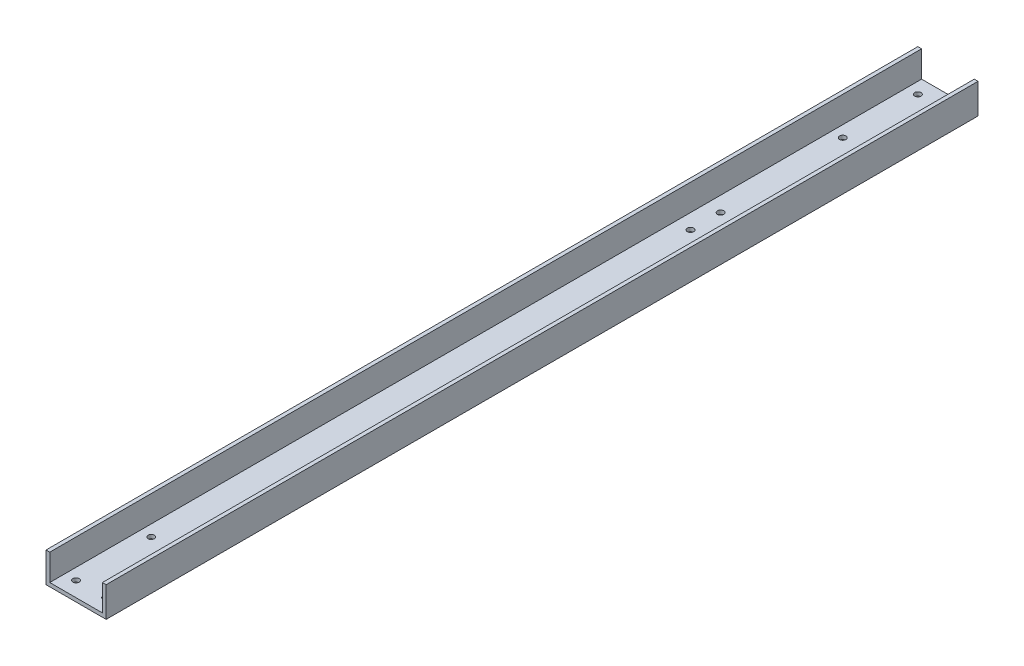
from build123d import *

# Parameters (mm, degrees)
EXTRUDE_F_DEPTH    = 736.6
CUT_EXTRUDE1_REACH = 5.175
SKETCH2_R          = 2.667
CUT_EXTRUDE2_REACH = 5.175
SKETCH3_R          = 2.667


with BuildPart() as part:
    # Sketch1 → Extrude f (new body)
    with BuildSketch(Plane.XY):
        Polygon((3.175, 3.175), (3.175, 25.4), (0, 25.4), (0, 0), (50.8, 0), (50.8, 25.4), (47.625, 25.4), (47.625, 3.175), align=None)
    extrude(amount=EXTRUDE_F_DEPTH)

    # Sketch2 → Cut-Extrude1 (cut, up to next)
    with BuildSketch(Plane(origin=(0, 3.175, 0), x_dir=(1, 0, 0), z_dir=(0, 1, 0)), mode=Mode.PRIVATE) as cut_extrude1_sk1:
        with Locations((12.7, -723.9)):
            Circle(SKETCH2_R)
    cut_extrude1_tool1 = extrude(cut_extrude1_sk1.sketch, amount=-CUT_EXTRUDE1_REACH, mode=Mode.PRIVATE) & part.part
    add(cut_extrude1_tool1.solids().sort_by_distance((12.7, 3.175, 723.9))[0], mode=Mode.SUBTRACT)
    # Sketch2 → Cut-Extrude1 (cut, up to next)
    with BuildSketch(Plane(origin=(0, 3.175, 0), x_dir=(1, 0, 0), z_dir=(0, 1, 0)), mode=Mode.PRIVATE) as cut_extrude1_sk2:
        with Locations((12.7, -660.4)):
            Circle(SKETCH2_R)
    cut_extrude1_tool2 = extrude(cut_extrude1_sk2.sketch, amount=-CUT_EXTRUDE1_REACH, mode=Mode.PRIVATE) & part.part
    add(cut_extrude1_tool2.solids().sort_by_distance((12.7, 3.175, 660.4))[0], mode=Mode.SUBTRACT)
    # Sketch2 → Cut-Extrude1 (cut, up to next)
    with BuildSketch(Plane(origin=(0, 3.175, 0), x_dir=(1, 0, 0), z_dir=(0, 1, 0)), mode=Mode.PRIVATE) as cut_extrude1_sk3:
        with Locations((38.1, -660.4)):
            Circle(SKETCH2_R)
    cut_extrude1_tool3 = extrude(cut_extrude1_sk3.sketch, amount=-CUT_EXTRUDE1_REACH, mode=Mode.PRIVATE) & part.part
    add(cut_extrude1_tool3.solids().sort_by_distance((38.1, 3.175, 660.4))[0], mode=Mode.SUBTRACT)
    # Sketch2 → Cut-Extrude1 (cut, up to next)
    with BuildSketch(Plane(origin=(0, 3.175, 0), x_dir=(1, 0, 0), z_dir=(0, 1, 0)), mode=Mode.PRIVATE) as cut_extrude1_sk4:
        with Locations((38.1, -723.9)):
            Circle(SKETCH2_R)
    cut_extrude1_tool4 = extrude(cut_extrude1_sk4.sketch, amount=-CUT_EXTRUDE1_REACH, mode=Mode.PRIVATE) & part.part
    add(cut_extrude1_tool4.solids().sort_by_distance((38.1, 3.175, 723.9))[0], mode=Mode.SUBTRACT)
    # Sketch2 → Cut-Extrude1 (cut, up to next)
    with BuildSketch(Plane(origin=(0, 3.175, 0), x_dir=(1, 0, 0), z_dir=(0, 1, 0)), mode=Mode.PRIVATE) as cut_extrude1_sk5:
        with Locations((38.1, -12.7)):
            Circle(SKETCH2_R)
    cut_extrude1_tool5 = extrude(cut_extrude1_sk5.sketch, amount=-CUT_EXTRUDE1_REACH, mode=Mode.PRIVATE) & part.part
    add(cut_extrude1_tool5.solids().sort_by_distance((38.1, 3.175, 12.7))[0], mode=Mode.SUBTRACT)
    # Sketch2 → Cut-Extrude1 (cut, up to next)
    with BuildSketch(Plane(origin=(0, 3.175, 0), x_dir=(1, 0, 0), z_dir=(0, 1, 0)), mode=Mode.PRIVATE) as cut_extrude1_sk6:
        with Locations((38.1, -76.2)):
            Circle(SKETCH2_R)
    cut_extrude1_tool6 = extrude(cut_extrude1_sk6.sketch, amount=-CUT_EXTRUDE1_REACH, mode=Mode.PRIVATE) & part.part
    add(cut_extrude1_tool6.solids().sort_by_distance((38.1, 3.175, 76.2))[0], mode=Mode.SUBTRACT)
    # Sketch2 → Cut-Extrude1 (cut, up to next)
    with BuildSketch(Plane(origin=(0, 3.175, 0), x_dir=(1, 0, 0), z_dir=(0, 1, 0)), mode=Mode.PRIVATE) as cut_extrude1_sk7:
        with Locations((12.7, -12.7)):
            Circle(SKETCH2_R)
    cut_extrude1_tool7 = extrude(cut_extrude1_sk7.sketch, amount=-CUT_EXTRUDE1_REACH, mode=Mode.PRIVATE) & part.part
    add(cut_extrude1_tool7.solids().sort_by_distance((12.7, 3.175, 12.7))[0], mode=Mode.SUBTRACT)
    # Sketch2 → Cut-Extrude1 (cut, up to next)
    with BuildSketch(Plane(origin=(0, 3.175, 0), x_dir=(1, 0, 0), z_dir=(0, 1, 0)), mode=Mode.PRIVATE) as cut_extrude1_sk8:
        with Locations((12.7, -76.2)):
            Circle(SKETCH2_R)
    cut_extrude1_tool8 = extrude(cut_extrude1_sk8.sketch, amount=-CUT_EXTRUDE1_REACH, mode=Mode.PRIVATE) & part.part
    add(cut_extrude1_tool8.solids().sort_by_distance((12.7, 3.175, 76.2))[0], mode=Mode.SUBTRACT)

    # Sketch3 → Cut-Extrude2 (cut, up to next)
    with BuildSketch(Plane(origin=(0, 3.175, 0), x_dir=(1, 0, 0), z_dir=(0, 1, 0)), mode=Mode.PRIVATE) as cut_extrude2_sk1:
        with Locations((34.925, -207.9371)):
            Circle(SKETCH3_R)
    cut_extrude2_tool1 = extrude(cut_extrude2_sk1.sketch, amount=-CUT_EXTRUDE2_REACH, mode=Mode.PRIVATE) & part.part
    add(cut_extrude2_tool1.solids().sort_by_distance((34.925, 3.175, 207.9371))[0], mode=Mode.SUBTRACT)
    # Sketch3 → Cut-Extrude2 (cut, up to next)
    with BuildSketch(Plane(origin=(0, 3.175, 0), x_dir=(1, 0, 0), z_dir=(0, 1, 0)), mode=Mode.PRIVATE) as cut_extrude2_sk2:
        with Locations((15.875, -207.9371)):
            Circle(SKETCH3_R)
    cut_extrude2_tool2 = extrude(cut_extrude2_sk2.sketch, amount=-CUT_EXTRUDE2_REACH, mode=Mode.PRIVATE) & part.part
    add(cut_extrude2_tool2.solids().sort_by_distance((15.875, 3.175, 207.9371))[0], mode=Mode.SUBTRACT)
    # Sketch3 → Cut-Extrude2 (cut, up to next)
    with BuildSketch(Plane(origin=(0, 3.175, 0), x_dir=(1, 0, 0), z_dir=(0, 1, 0)), mode=Mode.PRIVATE) as cut_extrude2_sk3:
        with Locations((34.925, -182.5371)):
            Circle(SKETCH3_R)
    cut_extrude2_tool3 = extrude(cut_extrude2_sk3.sketch, amount=-CUT_EXTRUDE2_REACH, mode=Mode.PRIVATE) & part.part
    add(cut_extrude2_tool3.solids().sort_by_distance((34.925, 3.175, 182.5371))[0], mode=Mode.SUBTRACT)
    # Sketch3 → Cut-Extrude2 (cut, up to next)
    with BuildSketch(Plane(origin=(0, 3.175, 0), x_dir=(1, 0, 0), z_dir=(0, 1, 0)), mode=Mode.PRIVATE) as cut_extrude2_sk4:
        with Locations((15.875, -182.5371)):
            Circle(SKETCH3_R)
    cut_extrude2_tool4 = extrude(cut_extrude2_sk4.sketch, amount=-CUT_EXTRUDE2_REACH, mode=Mode.PRIVATE) & part.part
    add(cut_extrude2_tool4.solids().sort_by_distance((15.875, 3.175, 182.5371))[0], mode=Mode.SUBTRACT)


solid = part.part
